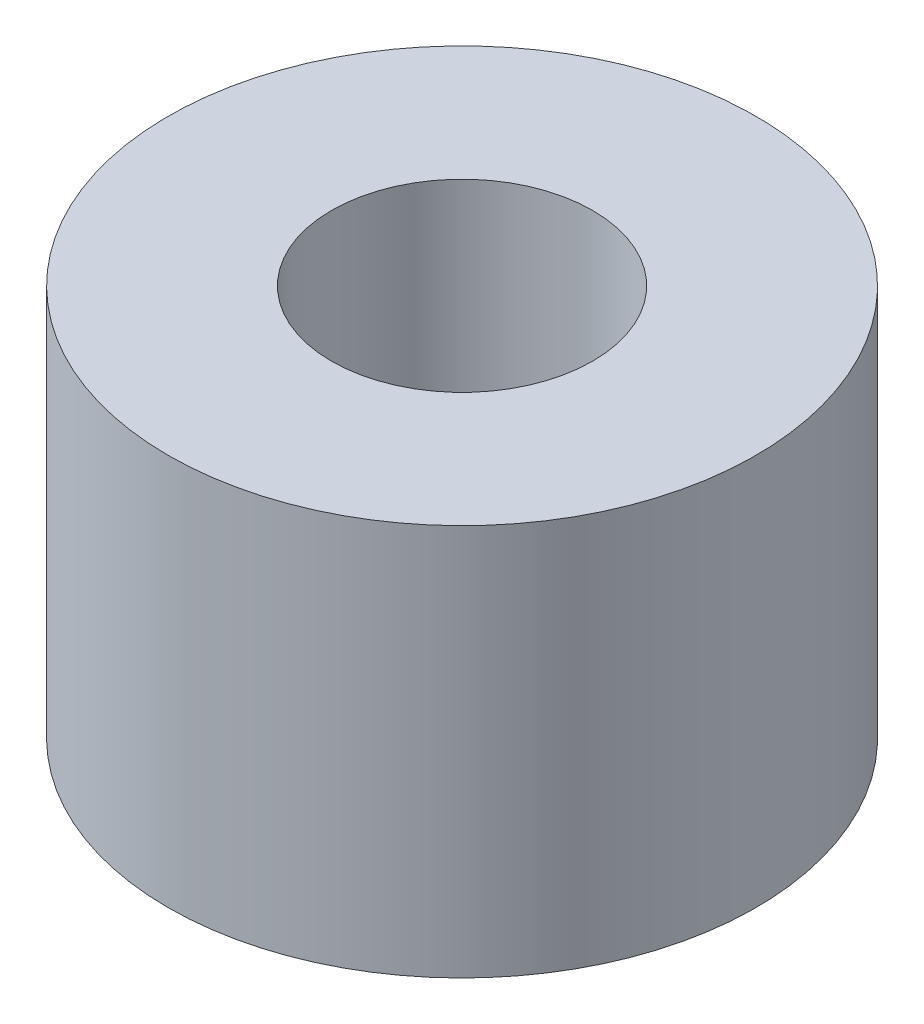
from build123d import *

# Parameters (mm, degrees)
SKETCH1_R           = 5.715
SKETCH1_R_2         = 2.54
BOSS_EXTRUDE1_DEPTH = 7.62


with BuildPart() as part:
    # Sketch1 → Boss-Extrude1 (new body)
    with BuildSketch(Plane(origin=(0, 0, 0), x_dir=(1, 0, 0), z_dir=(0, 1, 0))):
        Circle(SKETCH1_R)
        Circle(SKETCH1_R_2, mode=Mode.SUBTRACT)
    extrude(amount=BOSS_EXTRUDE1_DEPTH)


solid = part.part
